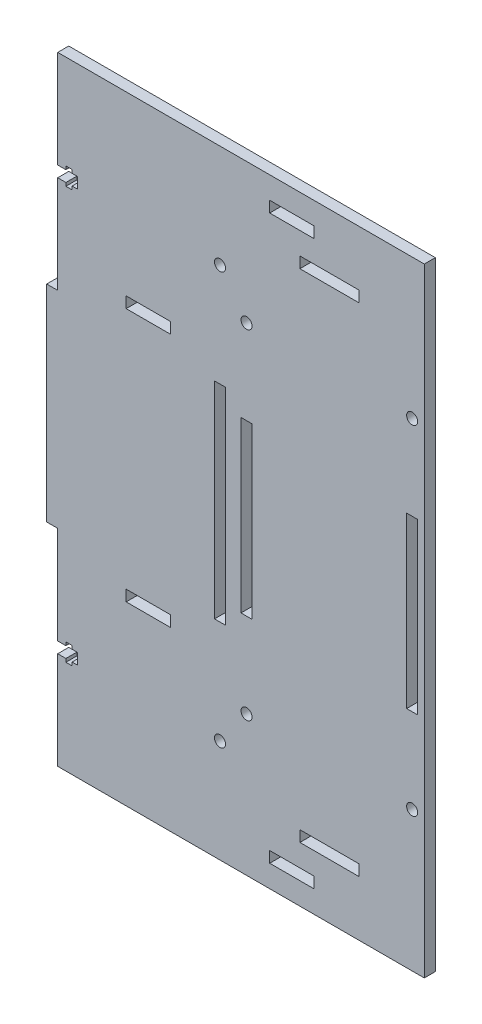
from build123d import *

# Parameters (mm, degrees)
CROQUIS1_W              = 5
CROQUIS1_H              = 93.333333334
SALIENTE_EXTRUIR1_DEPTH = 5
CORTAR_EXTRUIR1_DEPTH   = 5
CROQUIS3_W              = 5
CROQUIS3_H              = 93.333333334
CORTAR_EXTRUIR2_DEPTH   = 5
CROQUIS4_R              = 2.5
CORTAR_EXTRUIR3_DEPTH   = 5
CROQUIS5_W              = 20
CROQUIS5_H              = 5
CORTAR_EXTRUIR4_DEPTH   = 5
CROQUIS6_W              = 40
CROQUIS6_H              = 280
SALIENTE_EXTRUIR2_DEPTH = 5
CROQUIS7_W              = 5
CROQUIS7_H              = 76.666666666
CROQUIS7_W_2            = 26.666666666
CROQUIS7_H_2            = 5
CROQUIS7_R              = 2.5
CORTAR_EXTRUIR5_DEPTH   = 5


with BuildPart() as part:
    # Croquis1 → Saliente-Extruir1 (new body)
    with BuildSketch(Plane.XY):
        Polygon((5, 93.333333333), (5, 0), (131, 0), (131, 93.333333333), (131, 186.666666667), (131, 280), (5, 280), (5, 186.666666667), align=None)
        with Locations((2.5, 140)):
            Rectangle(CROQUIS1_W, CROQUIS1_H)
    extrude(amount=SALIENTE_EXTRUIR1_DEPTH)

    # Croquis2 → Cortar-Extruir1 (cut)
    with BuildSketch(Plane.XY.offset(5)):
        Polygon((8.7, 235.833333333), (5, 235.833333333), (5, 230.833333333), (8.7, 230.833333333), (8.7, 229.333333333), (11.5, 229.333333333), (11.5, 230.833333333), (14, 230.833333333), (14, 235.833333333), (11.5, 235.833333333), (11.5, 237.333333333), (8.7, 237.333333333), align=None)
        Polygon((8.7, 49.166666667), (5, 49.166666667), (5, 44.166666667), (8.7, 44.166666667), (8.7, 42.666666667), (11.5, 42.666666667), (11.5, 44.166666667), (14, 44.166666667), (14, 49.166666667), (11.5, 49.166666667), (11.5, 50.666666667), (8.7, 50.666666667), align=None)
    extrude(amount=-CORTAR_EXTRUIR1_DEPTH, mode=Mode.SUBTRACT)

    # Croquis3 → Cortar-Extruir2 (cut)
    with BuildSketch(Plane.XY.offset(5)):
        with Locations((78.5, 140)):
            Rectangle(CROQUIS3_W, CROQUIS3_H)
    extrude(amount=-CORTAR_EXTRUIR2_DEPTH, mode=Mode.SUBTRACT)

    # Croquis4 → Cortar-Extruir3 (cut)
    with BuildSketch(Plane.XY.offset(5)):
        with Locations((78.5, 233.333333333)):
            Circle(CROQUIS4_R)
        with Locations((78.5, 46.666666667)):
            Circle(CROQUIS4_R)
    extrude(amount=-CORTAR_EXTRUIR3_DEPTH, mode=Mode.SUBTRACT)

    # Croquis5 → Cortar-Extruir4 (cut)
    with BuildSketch(Plane.XY.offset(5)):
        with Locations((46, 197.5)):
            Rectangle(CROQUIS5_W, CROQUIS5_H)
        with Locations((111, 267.5)):
            Rectangle(CROQUIS5_W, CROQUIS5_H)
        with Locations((46, 82.5)):
            Rectangle(CROQUIS5_W, CROQUIS5_H)
        with Locations((111, 12.5)):
            Rectangle(CROQUIS5_W, CROQUIS5_H)
    extrude(amount=-CORTAR_EXTRUIR4_DEPTH, mode=Mode.SUBTRACT)

    # Croquis6 → Saliente-Extruir2 (add)
    with BuildSketch(Plane.XY.offset(5)):
        with Locations((151, 140)):
            Rectangle(CROQUIS6_W, CROQUIS6_H)
    extrude(amount=-SALIENTE_EXTRUIR2_DEPTH)

    # Croquis7 → Cortar-Extruir5 (cut)
    with BuildSketch(Plane.XY.offset(5)):
        with Locations((90.5, 140)):
            Rectangle(CROQUIS7_W, CROQUIS7_H)
        with Locations((165.5, 140)):
            Rectangle(CROQUIS7_W, CROQUIS7_H)
        with Locations((128, 27.5)):
            Rectangle(CROQUIS7_W_2, CROQUIS7_H_2)
        with Locations((128, 252.5)):
            Rectangle(CROQUIS7_W_2, CROQUIS7_H_2)
        with Locations((90.5, 216.666666667)):
            Circle(CROQUIS7_R)
        with Locations((165.5, 216.666666667)):
            Circle(CROQUIS7_R)
        with Locations((165.5, 63.333333333)):
            Circle(CROQUIS7_R)
        with Locations((90.5, 63.333333333)):
            Circle(CROQUIS7_R)
    extrude(amount=-CORTAR_EXTRUIR5_DEPTH, mode=Mode.SUBTRACT)


solid = part.part
